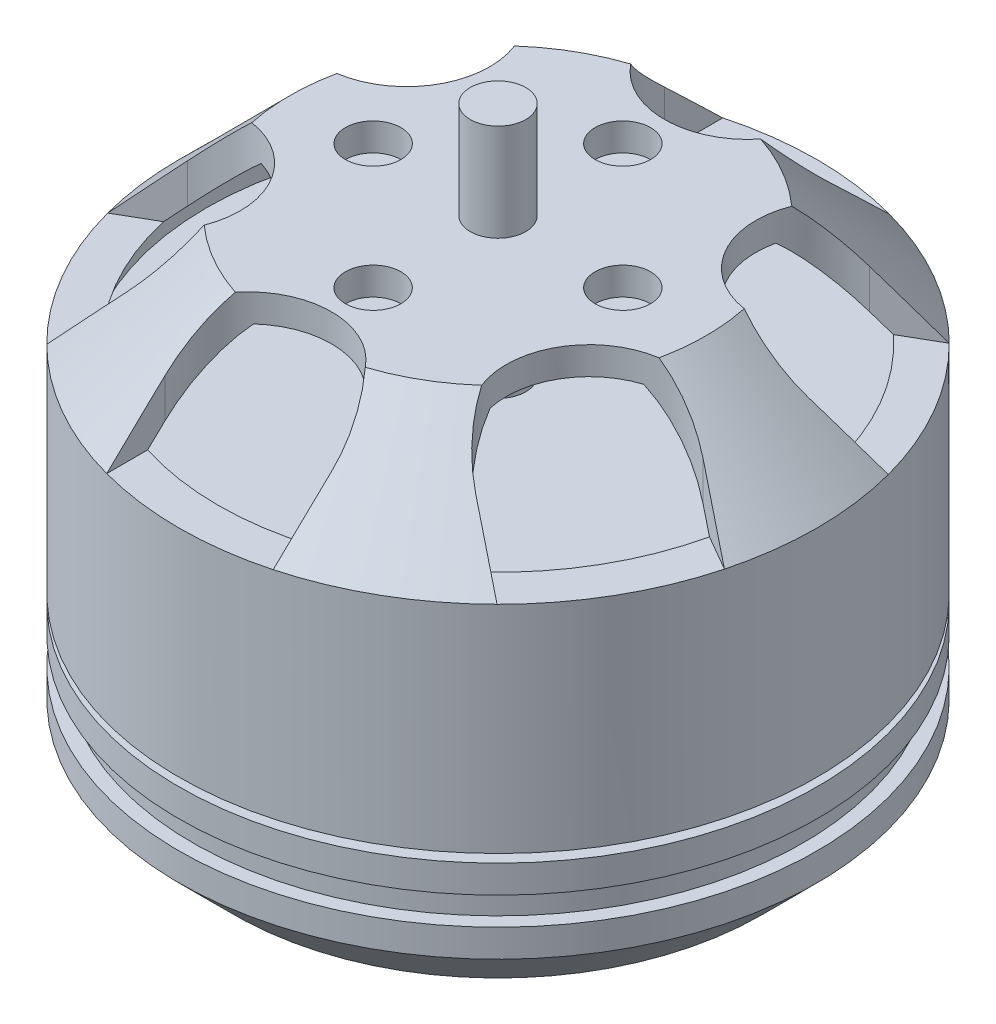
from build123d import *

# Parameters (mm, degrees)
SKETCH4_R          = 1.1
CUT_EXTRUDE1_DEPTH = 3.5
SKETCH5_R          = 1
CUT_EXTRUDE2_DEPTH = 4


with BuildPart() as part:
    # Sketch2 → Revolve1 (revolve)
    with BuildSketch(Plane.XY):
        Polygon((0, 0), (-1, 0), (-1, -22.38), (0, -22.38), (0, -20.58), (8.5, -20.58), (10.5, -18.58), (10.5, -17.58), (10, -17.58), (10, -16.58), (10.5, -16.58), (10.5, -15.58), (8.5, -15.58), (8.5, -15.28), (10.5, -15.28), (10.5, -7.5), (6.5, -3.5), (0, -3.5), align=None)
        Polygon((1, -4.5), (6.085786438, -4.5), (9.5, -7.914213562), (9.5, -8.5), (0, -8.5), (0, -5.5), (1, -5.5), align=None, mode=Mode.SUBTRACT)
    revolve(axis=Axis((-1, 0, 0), (0, -1, 0)))

    # Sketch4 → Cut-Extrude1 (cut)
    with BuildSketch(Plane.XZ.offset(20.58)):
        with Locations((-1, 5)):
            Circle(SKETCH4_R)
        with Locations((4, 0)):
            Circle(SKETCH4_R)
        with Locations((-1, -5)):
            Circle(SKETCH4_R)
        with Locations((-6, 0)):
            Circle(SKETCH4_R)
    extrude(amount=-CUT_EXTRUDE1_DEPTH, mode=Mode.SUBTRACT)

    # Sketch5 → Cut-Extrude2 (cut)
    with BuildSketch(Plane(origin=(0, -3.5, 0), x_dir=(1, 0, 0), z_dir=(0, 1, 0))):
        with Locations((-1, 4.5)):
            Circle(SKETCH5_R)
        with Locations((3.5, 0)):
            Circle(SKETCH5_R)
        with Locations((-1, -4.5)):
            Circle(SKETCH5_R)
        with Locations((-5.5, 0)):
            Circle(SKETCH5_R)
        with BuildLine():
            Line((2, 9), (2, 12))
            Line((2, 12), (-4, 12))
            Line((-4, 12), (-4, 9))
            ThreePointArc((-4, 9), (-1, 6), (2, 9))
        make_face()
        with BuildLine():
            Line((8.294228634, 1.901923789), (10.892304845, 3.401923789))
            Line((10.892304845, 3.401923789), (7.892304845, 8.598076211))
            Line((7.892304845, 8.598076211), (5.294228634, 7.098076211))
            ThreePointArc((5.294228634, 7.098076211), (4.196152423, 3), (8.294228634, 1.901923789))
        make_face()
        with BuildLine():
            Line((5.294228634, -7.098076211), (7.892304845, -8.598076211))
            Line((7.892304845, -8.598076211), (10.892304845, -3.401923789))
            Line((10.892304845, -3.401923789), (8.294228634, -1.901923789))
            ThreePointArc((8.294228634, -1.901923789), (4.196152423, -3), (5.294228634, -7.098076211))
        make_face()
        with BuildLine():
            Line((-4, -9), (-4, -12))
            Line((-4, -12), (2, -12))
            Line((2, -12), (2, -9))
            ThreePointArc((2, -9), (-1, -6), (-4, -9))
        make_face()
        with BuildLine():
            Line((-10.294228634, -1.901923789), (-12.892304845, -3.401923789))
            Line((-12.892304845, -3.401923789), (-9.892304845, -8.598076211))
            Line((-9.892304845, -8.598076211), (-7.294228634, -7.098076211))
            ThreePointArc((-7.294228634, -7.098076211), (-6.196152423, -3), (-10.294228634, -1.901923789))
        make_face()
        with BuildLine():
            Line((-7.294228634, 7.098076211), (-9.892304845, 8.598076211))
            Line((-9.892304845, 8.598076211), (-12.892304845, 3.401923789))
            Line((-12.892304845, 3.401923789), (-10.294228634, 1.901923789))
            ThreePointArc((-10.294228634, 1.901923789), (-6.196152423, 3), (-7.294228634, 7.098076211))
        make_face()
    extrude(amount=-CUT_EXTRUDE2_DEPTH, mode=Mode.SUBTRACT)


solid = part.part
